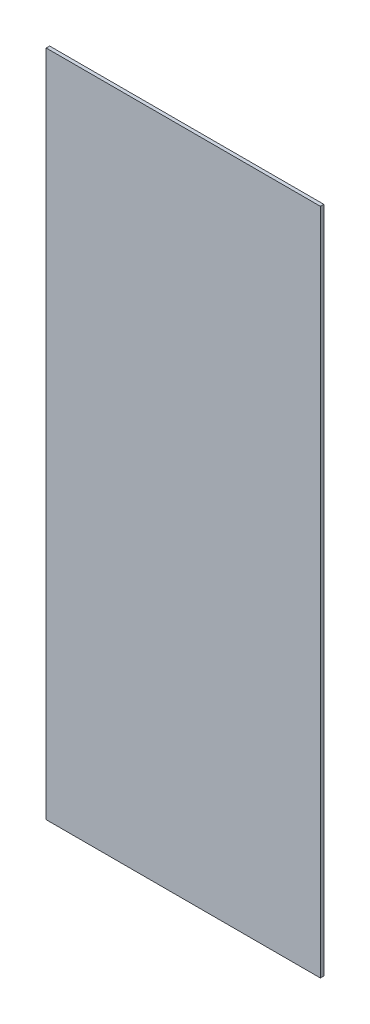
from build123d import *

# Parameters (mm, degrees)
SKETCH1_W           = 79.585954278
SKETCH1_H           = 194
BOSS_EXTRUDE1_DEPTH = 1


with BuildPart() as part:
    # Sketch1 → Boss-Extrude1 (new body)
    with BuildSketch(Plane.XY):
        with Locations((345.458658295, -35.372707696)):
            Rectangle(SKETCH1_W, SKETCH1_H)
    extrude(amount=BOSS_EXTRUDE1_DEPTH)


solid = part.part
